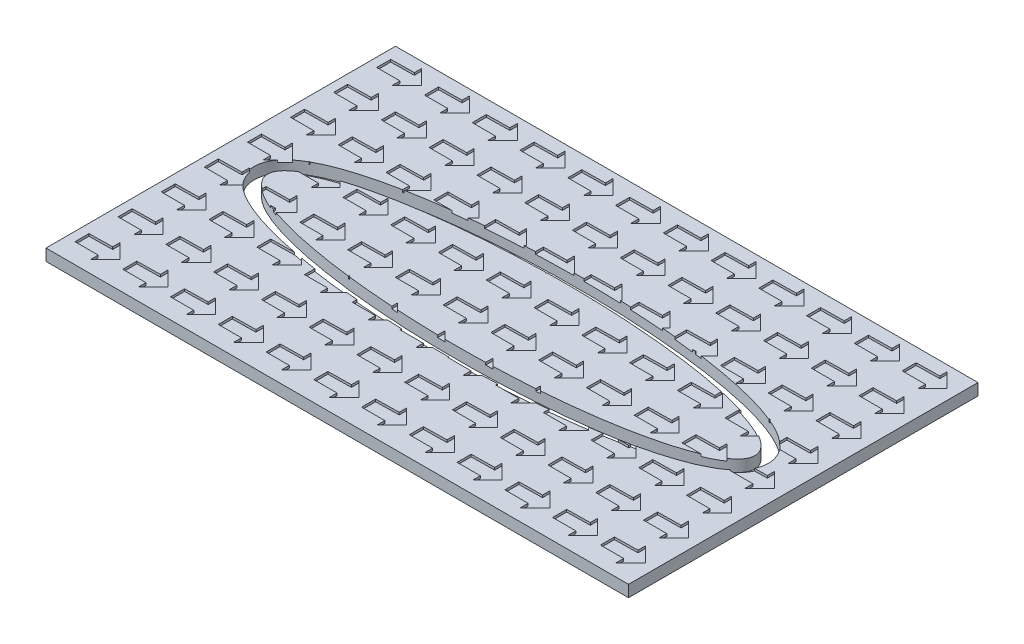
from build123d import *

# Parameters (mm, degrees)
SKETCH1_W           = 250
SKETCH1_H           = 150
BOSS_EXTRUDE1_DEPTH = 5
SKETCH2_RX          = 104.608369869
SKETCH2_RY          = 23.310401113
CUT_EXTRUDE1_DEPTH  = 5
CUT_EXTRUDE2_DEPTH  = 1


with BuildPart() as part:
    # Sketch1 → Boss-Extrude1 (new body)
    with BuildSketch(Plane(origin=(0, 0, 0), x_dir=(1, 0, 0), z_dir=(0, 1, 0))):
        with Locations((125, 75)):
            Rectangle(SKETCH1_W, SKETCH1_H)
    extrude(amount=BOSS_EXTRUDE1_DEPTH)

    # Sketch2 → Cut-Extrude1 (cut)
    with BuildSketch(Plane(origin=(0, 5, 0), x_dir=(1, 0, 0), z_dir=(0, 1, 0))):
        with BuildLine():
            add(Edge.make_bspline(
                [(14.340715902, 75), (14.340715902, 73.403382878), (15.092578894, 70.210148633), (17.677509801, 66.497889699), (21.067661583, 63.528997923), (25.203326141, 60.970996136), (30.102573384, 58.669625264), (37.666753171, 55.861830063), (49.028889113, 52.784952356), (65.375714852, 49.798065003), (83.889689518, 47.594262181), (103.910053835, 46.241449203), (124.701337221, 45.785296554), (145.492620606, 46.241449203), (165.512984923, 47.594262181), (184.026959589, 49.798065003), (200.373785328, 52.784952356), (211.73592127, 55.861830063), (219.300101057, 58.669625264), (224.199348301, 60.970996136), (228.335012859, 63.528997923), (231.725164641, 66.497889699), (234.310095547, 70.210148633), (235.437890036, 75), (234.310095547, 79.789851367), (231.725164641, 83.502110301), (228.335012859, 86.471002077), (224.199348301, 89.029003864), (219.300101057, 91.330374736), (211.73592127, 94.138169937), (200.373785328, 97.215047644), (184.026959589, 100.201934997), (165.512984923, 102.405737819), (145.492620606, 103.758550797), (124.701337221, 104.214703446), (103.910053835, 103.758550797), (83.889689518, 102.405737819), (65.375714852, 100.201934997), (49.028889113, 97.215047644), (37.666753171, 94.138169937), (30.102573384, 91.330374736), (25.203326141, 89.029003864), (21.067661583, 86.471002077), (17.677509801, 83.502110301), (15.092578894, 79.789851367), (14.340715902, 76.596617122), (14.340715902, 75)],
                knots=[0, 0, 0, 0, 0.09817477, 0.196349541, 0.294524311, 0.392699082, 0.490873852, 0.589048623, 0.785398163, 0.981747704, 1.178097245, 1.374446786, 1.570796327, 1.767145868, 1.963495408, 2.159844949, 2.35619449, 2.552544031, 2.650718801, 2.748893572, 2.847068342, 2.945243113, 3.043417883, 3.141592654, 3.239767424, 3.337942194, 3.436116965, 3.534291735, 3.632466506, 3.730641276, 3.926990817, 4.123340358, 4.319689899, 4.51603944, 4.71238898, 4.908738521, 5.105088062, 5.301437603, 5.497787144, 5.694136685, 5.792311455, 5.890486225, 5.988660996, 6.086835766, 6.185010537, 6.283185307, 6.283185307, 6.283185307, 6.283185307], degree=3))
        make_face()
        with Locations((124.701337221, 75)):
            Ellipse(SKETCH2_RX, SKETCH2_RY, mode=Mode.SUBTRACT)
    extrude(amount=-CUT_EXTRUDE1_DEPTH, mode=Mode.SUBTRACT)


with BuildPart() as cut_extrude1_piece_1:
    # of the separate pieces the step leaves, piece 1, a body of its own (cut_extrude1_pieces)
    add(part.part.solids().sort_by_distance((0, 0, 0))[0])


with BuildPart() as cut_extrude1_piece_2:
    # of the separate pieces the step leaves, piece 2, a body of its own (cut_extrude1_pieces)
    add(part.part.solids().sort_by_distance((229.30970709, 0, -75))[0])


with BuildPart() as cut_extrude2_tool:
    # Sketch3 → Cut-Extrude2 (new body)
    with BuildSketch(Plane(origin=(0, 5, 0), x_dir=(1, 0, 0), z_dir=(0, 1, 0))):
        Polygon((3.872279996, 144.087272639), (3.872279996, 138.072450962), (13.844221197, 138.072450962), (13.844221197, 134.748470562), (20.175612436, 141.079861801), (13.844221197, 147.411253039), (13.844221197, 144.24555742), align=None)
        Polygon((24.372279996, 144.087272639), (24.372279996, 138.072450962), (34.344221197, 138.072450962), (34.344221197, 134.748470562), (40.675612436, 141.079861801), (34.344221197, 147.411253039), (34.344221197, 144.24555742), align=None)
        Polygon((44.872279996, 144.087272639), (44.872279996, 138.072450962), (54.844221197, 138.072450962), (54.844221197, 134.748470562), (61.175612436, 141.079861801), (54.844221197, 147.411253039), (54.844221197, 144.24555742), align=None)
        Polygon((65.372279996, 144.087272639), (65.372279996, 138.072450962), (75.344221197, 138.072450962), (75.344221197, 134.748470562), (81.675612436, 141.079861801), (75.344221197, 147.411253039), (75.344221197, 144.24555742), align=None)
        Polygon((85.872279996, 144.087272639), (85.872279996, 138.072450962), (95.844221197, 138.072450962), (95.844221197, 134.748470562), (102.175612436, 141.079861801), (95.844221197, 147.411253039), (95.844221197, 144.24555742), align=None)
        Polygon((106.372279996, 144.087272639), (106.372279996, 138.072450962), (116.344221197, 138.072450962), (116.344221197, 134.748470562), (122.675612436, 141.079861801), (116.344221197, 147.411253039), (116.344221197, 144.24555742), align=None)
        Polygon((126.872279996, 144.087272639), (126.872279996, 138.072450962), (136.844221197, 138.072450962), (136.844221197, 134.748470562), (143.175612436, 141.079861801), (136.844221197, 147.411253039), (136.844221197, 144.24555742), align=None)
        Polygon((147.372279996, 144.087272639), (147.372279996, 138.072450962), (157.344221197, 138.072450962), (157.344221197, 134.748470562), (163.675612435, 141.079861801), (157.344221197, 147.411253039), (157.344221197, 144.24555742), align=None)
        Polygon((167.872279996, 144.087272639), (167.872279996, 138.072450962), (177.844221197, 138.072450962), (177.844221197, 134.748470562), (184.175612435, 141.079861801), (177.844221197, 147.411253039), (177.844221197, 144.24555742), align=None)
        Polygon((188.372279996, 144.087272639), (188.372279996, 138.072450962), (198.344221197, 138.072450962), (198.344221197, 134.748470562), (204.675612435, 141.079861801), (198.344221197, 147.411253039), (198.344221197, 144.24555742), align=None)
        Polygon((208.872279996, 144.087272639), (208.872279996, 138.072450962), (218.844221197, 138.072450962), (218.844221197, 134.748470562), (225.175612435, 141.079861801), (218.844221197, 147.411253039), (218.844221197, 144.24555742), align=None)
        Polygon((229.372279996, 144.087272639), (229.372279996, 138.072450962), (239.344221197, 138.072450962), (239.344221197, 134.748470562), (245.675612435, 141.079861801), (239.344221197, 147.411253039), (239.344221197, 144.24555742), align=None)
        Polygon((24.372279996, 125.587272639), (24.372279996, 119.572450962), (34.344221197, 119.572450962), (34.344221197, 116.248470562), (40.675612436, 122.579861801), (34.344221197, 128.911253039), (34.344221197, 125.74555742), align=None)
        Polygon((44.872279996, 125.587272639), (44.872279996, 119.572450962), (54.844221197, 119.572450962), (54.844221197, 116.248470562), (61.175612436, 122.579861801), (54.844221197, 128.911253039), (54.844221197, 125.74555742), align=None)
        Polygon((65.372279996, 125.587272639), (65.372279996, 119.572450962), (75.344221197, 119.572450962), (75.344221197, 116.248470562), (81.675612436, 122.579861801), (75.344221197, 128.911253039), (75.344221197, 125.74555742), align=None)
        Polygon((85.872279996, 125.587272639), (85.872279996, 119.572450962), (95.844221197, 119.572450962), (95.844221197, 116.248470562), (102.175612436, 122.579861801), (95.844221197, 128.911253039), (95.844221197, 125.74555742), align=None)
        Polygon((106.372279996, 125.587272639), (106.372279996, 119.572450962), (116.344221197, 119.572450962), (116.344221197, 116.248470562), (122.675612436, 122.579861801), (116.344221197, 128.911253039), (116.344221197, 125.74555742), align=None)
        Polygon((126.872279996, 125.587272639), (126.872279996, 119.572450962), (136.844221197, 119.572450962), (136.844221197, 116.248470562), (143.175612436, 122.579861801), (136.844221197, 128.911253039), (136.844221197, 125.74555742), align=None)
        Polygon((147.372279996, 125.587272639), (147.372279996, 119.572450962), (157.344221197, 119.572450962), (157.344221197, 116.248470562), (163.675612435, 122.579861801), (157.344221197, 128.911253039), (157.344221197, 125.74555742), align=None)
        Polygon((167.872279996, 125.587272639), (167.872279996, 119.572450962), (177.844221197, 119.572450962), (177.844221197, 116.248470562), (184.175612435, 122.579861801), (177.844221197, 128.911253039), (177.844221197, 125.74555742), align=None)
        Polygon((188.372279996, 125.587272639), (188.372279996, 119.572450962), (198.344221197, 119.572450962), (198.344221197, 116.248470562), (204.675612435, 122.579861801), (198.344221197, 128.911253039), (198.344221197, 125.74555742), align=None)
        Polygon((208.872279996, 125.587272639), (208.872279996, 119.572450962), (218.844221197, 119.572450962), (218.844221197, 116.248470562), (225.175612435, 122.579861801), (218.844221197, 128.911253039), (218.844221197, 125.74555742), align=None)
        Polygon((229.372279996, 125.587272639), (229.372279996, 119.572450962), (239.344221197, 119.572450962), (239.344221197, 116.248470562), (245.675612435, 122.579861801), (239.344221197, 128.911253039), (239.344221197, 125.74555742), align=None)
        Polygon((24.372279996, 107.087272639), (24.372279996, 101.072450962), (34.344221197, 101.072450962), (34.344221197, 97.748470562), (40.675612436, 104.079861801), (34.344221197, 110.411253039), (34.344221197, 107.24555742), align=None)
        Polygon((44.872279996, 107.087272639), (44.872279996, 101.072450962), (54.844221197, 101.072450962), (54.844221197, 97.748470562), (61.175612436, 104.079861801), (54.844221197, 110.411253039), (54.844221197, 107.24555742), align=None)
        Polygon((65.372279996, 107.087272639), (65.372279996, 101.072450962), (75.344221197, 101.072450962), (75.344221197, 97.748470562), (81.675612436, 104.079861801), (75.344221197, 110.411253039), (75.344221197, 107.24555742), align=None)
        Polygon((85.872279996, 107.087272639), (85.872279996, 101.072450962), (95.844221197, 101.072450962), (95.844221197, 97.748470562), (102.175612436, 104.079861801), (95.844221197, 110.411253039), (95.844221197, 107.24555742), align=None)
        Polygon((106.372279996, 107.087272639), (106.372279996, 101.072450962), (116.344221197, 101.072450962), (116.344221197, 97.748470562), (122.675612436, 104.079861801), (116.344221197, 110.411253039), (116.344221197, 107.24555742), align=None)
        Polygon((126.872279996, 107.087272639), (126.872279996, 101.072450962), (136.844221197, 101.072450962), (136.844221197, 97.748470562), (143.175612436, 104.079861801), (136.844221197, 110.411253039), (136.844221197, 107.24555742), align=None)
        Polygon((147.372279996, 107.087272639), (147.372279996, 101.072450962), (157.344221197, 101.072450962), (157.344221197, 97.748470562), (163.675612436, 104.079861801), (157.344221197, 110.411253039), (157.344221197, 107.24555742), align=None)
        Polygon((167.872279996, 107.087272639), (167.872279996, 101.072450962), (177.844221197, 101.072450962), (177.844221197, 97.748470562), (184.175612435, 104.079861801), (177.844221197, 110.411253039), (177.844221197, 107.24555742), align=None)
        Polygon((188.372279996, 107.087272639), (188.372279996, 101.072450962), (198.344221197, 101.072450962), (198.344221197, 97.748470562), (204.675612435, 104.079861801), (198.344221197, 110.411253039), (198.344221197, 107.24555742), align=None)
        Polygon((208.872279996, 107.087272639), (208.872279996, 101.072450962), (218.844221197, 101.072450962), (218.844221197, 97.748470562), (225.175612435, 104.079861801), (218.844221197, 110.411253039), (218.844221197, 107.24555742), align=None)
        Polygon((229.372279996, 107.087272639), (229.372279996, 101.072450962), (239.344221197, 101.072450962), (239.344221197, 97.748470562), (245.675612435, 104.079861801), (239.344221197, 110.411253039), (239.344221197, 107.24555742), align=None)
        Polygon((24.372279996, 88.587272639), (24.372279996, 82.572450962), (34.344221197, 82.572450962), (34.344221197, 79.248470562), (40.675612436, 85.579861801), (34.344221197, 91.911253039), (34.344221197, 88.74555742), align=None)
        Polygon((44.872279996, 88.587272639), (44.872279996, 82.572450962), (54.844221197, 82.572450962), (54.844221197, 79.248470562), (61.175612436, 85.579861801), (54.844221197, 91.911253039), (54.844221197, 88.74555742), align=None)
        Polygon((65.372279996, 88.587272639), (65.372279996, 82.572450962), (75.344221197, 82.572450962), (75.344221197, 79.248470562), (81.675612436, 85.579861801), (75.344221197, 91.911253039), (75.344221197, 88.74555742), align=None)
        Polygon((85.872279996, 88.587272639), (85.872279996, 82.572450962), (95.844221197, 82.572450962), (95.844221197, 79.248470562), (102.175612436, 85.579861801), (95.844221197, 91.911253039), (95.844221197, 88.74555742), align=None)
        Polygon((106.372279996, 88.587272639), (106.372279996, 82.572450962), (116.344221197, 82.572450962), (116.344221197, 79.248470562), (122.675612436, 85.579861801), (116.344221197, 91.911253039), (116.344221197, 88.74555742), align=None)
        Polygon((126.872279996, 88.587272639), (126.872279996, 82.572450962), (136.844221197, 82.572450962), (136.844221197, 79.248470562), (143.175612436, 85.579861801), (136.844221197, 91.911253039), (136.844221197, 88.74555742), align=None)
        Polygon((147.372279996, 88.587272639), (147.372279996, 82.572450962), (157.344221197, 82.572450962), (157.344221197, 79.248470562), (163.675612436, 85.579861801), (157.344221197, 91.911253039), (157.344221197, 88.74555742), align=None)
        Polygon((167.872279996, 88.587272639), (167.872279996, 82.572450962), (177.844221197, 82.572450962), (177.844221197, 79.248470562), (184.175612435, 85.579861801), (177.844221197, 91.911253039), (177.844221197, 88.74555742), align=None)
        Polygon((188.372279996, 88.587272639), (188.372279996, 82.572450962), (198.344221197, 82.572450962), (198.344221197, 79.248470562), (204.675612435, 85.579861801), (198.344221197, 91.911253039), (198.344221197, 88.74555742), align=None)
        Polygon((208.872279996, 88.587272639), (208.872279996, 82.572450962), (218.844221197, 82.572450962), (218.844221197, 79.248470562), (225.175612435, 85.579861801), (218.844221197, 91.911253039), (218.844221197, 88.74555742), align=None)
        Polygon((229.372279996, 88.587272639), (229.372279996, 82.572450962), (239.344221197, 82.572450962), (239.344221197, 79.248470562), (245.675612435, 85.579861801), (239.344221197, 91.911253039), (239.344221197, 88.74555742), align=None)
        Polygon((24.372279996, 70.087272639), (24.372279996, 64.072450962), (34.344221197, 64.072450962), (34.344221197, 60.748470562), (40.675612436, 67.079861801), (34.344221197, 73.411253039), (34.344221197, 70.24555742), align=None)
        Polygon((44.872279996, 70.087272639), (44.872279996, 64.072450962), (54.844221197, 64.072450962), (54.844221197, 60.748470562), (61.175612436, 67.079861801), (54.844221197, 73.411253039), (54.844221197, 70.24555742), align=None)
        Polygon((65.372279996, 70.087272639), (65.372279996, 64.072450962), (75.344221197, 64.072450962), (75.344221197, 60.748470562), (81.675612436, 67.079861801), (75.344221197, 73.411253039), (75.344221197, 70.24555742), align=None)
        Polygon((85.872279996, 70.087272639), (85.872279996, 64.072450962), (95.844221197, 64.072450962), (95.844221197, 60.748470562), (102.175612436, 67.079861801), (95.844221197, 73.411253039), (95.844221197, 70.24555742), align=None)
        Polygon((106.372279996, 70.087272639), (106.372279996, 64.072450962), (116.344221197, 64.072450962), (116.344221197, 60.748470562), (122.675612436, 67.079861801), (116.344221197, 73.411253039), (116.344221197, 70.24555742), align=None)
        Polygon((126.872279996, 70.087272639), (126.872279996, 64.072450962), (136.844221197, 64.072450962), (136.844221197, 60.748470562), (143.175612436, 67.079861801), (136.844221197, 73.411253039), (136.844221197, 70.24555742), align=None)
        Polygon((147.372279996, 70.087272639), (147.372279996, 64.072450962), (157.344221197, 64.072450962), (157.344221197, 60.748470562), (163.675612436, 67.079861801), (157.344221197, 73.411253039), (157.344221197, 70.24555742), align=None)
        Polygon((167.872279996, 70.087272639), (167.872279996, 64.072450962), (177.844221197, 64.072450962), (177.844221197, 60.748470562), (184.175612435, 67.079861801), (177.844221197, 73.411253039), (177.844221197, 70.24555742), align=None)
        Polygon((188.372279996, 70.087272639), (188.372279996, 64.072450962), (198.344221197, 64.072450962), (198.344221197, 60.748470562), (204.675612435, 67.079861801), (198.344221197, 73.411253039), (198.344221197, 70.24555742), align=None)
        Polygon((208.872279996, 70.087272639), (208.872279996, 64.072450962), (218.844221197, 64.072450962), (218.844221197, 60.748470562), (225.175612435, 67.079861801), (218.844221197, 73.411253039), (218.844221197, 70.24555742), align=None)
        Polygon((229.372279996, 70.087272639), (229.372279996, 64.072450962), (239.344221197, 64.072450962), (239.344221197, 60.748470562), (245.675612435, 67.079861801), (239.344221197, 73.411253039), (239.344221197, 70.24555742), align=None)
        Polygon((24.372279996, 51.587272639), (24.372279996, 45.572450962), (34.344221197, 45.572450962), (34.344221197, 42.248470562), (40.675612436, 48.579861801), (34.344221197, 54.911253039), (34.344221197, 51.74555742), align=None)
        Polygon((44.872279996, 51.587272639), (44.872279996, 45.572450962), (54.844221197, 45.572450962), (54.844221197, 42.248470562), (61.175612436, 48.579861801), (54.844221197, 54.911253039), (54.844221197, 51.74555742), align=None)
        Polygon((65.372279996, 51.587272639), (65.372279996, 45.572450962), (75.344221197, 45.572450962), (75.344221197, 42.248470562), (81.675612436, 48.579861801), (75.344221197, 54.911253039), (75.344221197, 51.74555742), align=None)
        Polygon((85.872279996, 51.587272639), (85.872279996, 45.572450962), (95.844221197, 45.572450962), (95.844221197, 42.248470562), (102.175612436, 48.579861801), (95.844221197, 54.911253039), (95.844221197, 51.74555742), align=None)
        Polygon((106.372279996, 51.587272639), (106.372279996, 45.572450962), (116.344221197, 45.572450962), (116.344221197, 42.248470562), (122.675612436, 48.579861801), (116.344221197, 54.911253039), (116.344221197, 51.74555742), align=None)
        Polygon((126.872279996, 51.587272639), (126.872279996, 45.572450962), (136.844221197, 45.572450962), (136.844221197, 42.248470562), (143.175612436, 48.579861801), (136.844221197, 54.911253039), (136.844221197, 51.74555742), align=None)
        Polygon((147.372279996, 51.587272639), (147.372279996, 45.572450962), (157.344221197, 45.572450962), (157.344221197, 42.248470562), (163.675612436, 48.579861801), (157.344221197, 54.911253039), (157.344221197, 51.74555742), align=None)
        Polygon((167.872279996, 51.587272639), (167.872279996, 45.572450962), (177.844221197, 45.572450962), (177.844221197, 42.248470562), (184.175612435, 48.579861801), (177.844221197, 54.911253039), (177.844221197, 51.74555742), align=None)
        Polygon((188.372279996, 51.587272639), (188.372279996, 45.572450962), (198.344221197, 45.572450962), (198.344221197, 42.248470562), (204.675612435, 48.579861801), (198.344221197, 54.911253039), (198.344221197, 51.74555742), align=None)
        Polygon((208.872279996, 51.587272639), (208.872279996, 45.572450962), (218.844221197, 45.572450962), (218.844221197, 42.248470562), (225.175612435, 48.579861801), (218.844221197, 54.911253039), (218.844221197, 51.74555742), align=None)
        Polygon((229.372279996, 51.587272639), (229.372279996, 45.572450962), (239.344221197, 45.572450962), (239.344221197, 42.248470562), (245.675612435, 48.579861801), (239.344221197, 54.911253039), (239.344221197, 51.74555742), align=None)
        Polygon((24.372279996, 33.087272639), (24.372279996, 27.072450962), (34.344221197, 27.072450962), (34.344221197, 23.748470562), (40.675612436, 30.079861801), (34.344221197, 36.411253039), (34.344221197, 33.24555742), align=None)
        Polygon((44.872279996, 33.087272639), (44.872279996, 27.072450962), (54.844221197, 27.072450962), (54.844221197, 23.748470562), (61.175612436, 30.079861801), (54.844221197, 36.411253039), (54.844221197, 33.24555742), align=None)
        Polygon((65.372279996, 33.087272639), (65.372279996, 27.072450962), (75.344221197, 27.072450962), (75.344221197, 23.748470562), (81.675612436, 30.079861801), (75.344221197, 36.411253039), (75.344221197, 33.24555742), align=None)
        Polygon((85.872279996, 33.087272639), (85.872279996, 27.072450962), (95.844221197, 27.072450962), (95.844221197, 23.748470562), (102.175612436, 30.079861801), (95.844221197, 36.411253039), (95.844221197, 33.24555742), align=None)
        Polygon((106.372279996, 33.087272639), (106.372279996, 27.072450962), (116.344221197, 27.072450962), (116.344221197, 23.748470562), (122.675612436, 30.079861801), (116.344221197, 36.411253039), (116.344221197, 33.24555742), align=None)
        Polygon((126.872279996, 33.087272639), (126.872279996, 27.072450962), (136.844221197, 27.072450962), (136.844221197, 23.748470562), (143.175612436, 30.079861801), (136.844221197, 36.411253039), (136.844221197, 33.24555742), align=None)
        Polygon((147.372279996, 33.087272639), (147.372279996, 27.072450962), (157.344221197, 27.072450962), (157.344221197, 23.748470562), (163.675612436, 30.079861801), (157.344221197, 36.411253039), (157.344221197, 33.24555742), align=None)
        Polygon((167.872279996, 33.087272639), (167.872279996, 27.072450962), (177.844221197, 27.072450962), (177.844221197, 23.748470562), (184.175612435, 30.079861801), (177.844221197, 36.411253039), (177.844221197, 33.24555742), align=None)
        Polygon((188.372279996, 33.087272639), (188.372279996, 27.072450962), (198.344221197, 27.072450962), (198.344221197, 23.748470562), (204.675612435, 30.079861801), (198.344221197, 36.411253039), (198.344221197, 33.24555742), align=None)
        Polygon((208.872279996, 33.087272639), (208.872279996, 27.072450962), (218.844221197, 27.072450962), (218.844221197, 23.748470562), (225.175612435, 30.079861801), (218.844221197, 36.411253039), (218.844221197, 33.24555742), align=None)
        Polygon((229.372279996, 33.087272639), (229.372279996, 27.072450962), (239.344221197, 27.072450962), (239.344221197, 23.748470562), (245.675612435, 30.079861801), (239.344221197, 36.411253039), (239.344221197, 33.24555742), align=None)
        Polygon((24.372279996, 14.587272639), (24.372279996, 8.572450962), (34.344221197, 8.572450962), (34.344221197, 5.248470562), (40.675612436, 11.579861801), (34.344221197, 17.911253039), (34.344221197, 14.74555742), align=None)
        Polygon((44.872279996, 14.587272639), (44.872279996, 8.572450962), (54.844221197, 8.572450962), (54.844221197, 5.248470562), (61.175612436, 11.579861801), (54.844221197, 17.911253039), (54.844221197, 14.74555742), align=None)
        Polygon((65.372279996, 14.587272639), (65.372279996, 8.572450962), (75.344221197, 8.572450962), (75.344221197, 5.248470562), (81.675612436, 11.579861801), (75.344221197, 17.911253039), (75.344221197, 14.74555742), align=None)
        Polygon((85.872279996, 14.587272639), (85.872279996, 8.572450962), (95.844221197, 8.572450962), (95.844221197, 5.248470562), (102.175612436, 11.579861801), (95.844221197, 17.911253039), (95.844221197, 14.74555742), align=None)
        Polygon((106.372279996, 14.587272639), (106.372279996, 8.572450962), (116.344221197, 8.572450962), (116.344221197, 5.248470562), (122.675612436, 11.579861801), (116.344221197, 17.911253039), (116.344221197, 14.74555742), align=None)
        Polygon((126.872279996, 14.587272639), (126.872279996, 8.572450962), (136.844221197, 8.572450962), (136.844221197, 5.248470562), (143.175612436, 11.579861801), (136.844221197, 17.911253039), (136.844221197, 14.74555742), align=None)
        Polygon((147.372279996, 14.587272639), (147.372279996, 8.572450962), (157.344221197, 8.572450962), (157.344221197, 5.248470562), (163.675612436, 11.579861801), (157.344221197, 17.911253039), (157.344221197, 14.74555742), align=None)
        Polygon((167.872279996, 14.587272639), (167.872279996, 8.572450962), (177.844221197, 8.572450962), (177.844221197, 5.248470562), (184.175612435, 11.579861801), (177.844221197, 17.911253039), (177.844221197, 14.74555742), align=None)
        Polygon((188.372279996, 14.587272639), (188.372279996, 8.572450962), (198.344221197, 8.572450962), (198.344221197, 5.248470562), (204.675612435, 11.579861801), (198.344221197, 17.911253039), (198.344221197, 14.74555742), align=None)
        Polygon((208.872279996, 14.587272639), (208.872279996, 8.572450962), (218.844221197, 8.572450962), (218.844221197, 5.248470562), (225.175612435, 11.579861801), (218.844221197, 17.911253039), (218.844221197, 14.74555742), align=None)
        Polygon((229.372279996, 14.587272639), (229.372279996, 8.572450962), (239.344221197, 8.572450962), (239.344221197, 5.248470562), (245.675612435, 11.579861801), (239.344221197, 17.911253039), (239.344221197, 14.74555742), align=None)
        Polygon((3.872279996, 125.587272639), (3.872279996, 119.572450962), (13.844221197, 119.572450962), (13.844221197, 116.248470562), (20.175612436, 122.579861801), (13.844221197, 128.911253039), (13.844221197, 125.74555742), align=None)
        Polygon((3.872279996, 107.087272639), (3.872279996, 101.072450962), (13.844221197, 101.072450962), (13.844221197, 97.748470562), (20.175612436, 104.079861801), (13.844221197, 110.411253039), (13.844221197, 107.24555742), align=None)
        Polygon((3.872279996, 88.587272639), (3.872279996, 82.572450962), (13.844221197, 82.572450962), (13.844221197, 79.248470562), (20.175612436, 85.579861801), (13.844221197, 91.911253039), (13.844221197, 88.74555742), align=None)
        Polygon((3.872279996, 70.087272639), (3.872279996, 64.072450962), (13.844221197, 64.072450962), (13.844221197, 60.748470562), (20.175612436, 67.079861801), (13.844221197, 73.411253039), (13.844221197, 70.24555742), align=None)
        Polygon((3.872279996, 51.587272639), (3.872279996, 45.572450962), (13.844221197, 45.572450962), (13.844221197, 42.248470562), (20.175612436, 48.579861801), (13.844221197, 54.911253039), (13.844221197, 51.74555742), align=None)
        Polygon((3.872279996, 33.087272639), (3.872279996, 27.072450962), (13.844221197, 27.072450962), (13.844221197, 23.748470562), (20.175612436, 30.079861801), (13.844221197, 36.411253039), (13.844221197, 33.24555742), align=None)
        Polygon((3.872279996, 14.587272639), (3.872279996, 8.572450962), (13.844221197, 8.572450962), (13.844221197, 5.248470562), (20.175612436, 11.579861801), (13.844221197, 17.911253039), (13.844221197, 14.74555742), align=None)
    extrude(amount=-CUT_EXTRUDE2_DEPTH)


with BuildPart() as cut_extrude1_piece_1_1:
    add(cut_extrude1_piece_1.part)

    # Cut-Extrude2: cut by cut_extrude2_tool
    add(cut_extrude2_tool.part, mode=Mode.SUBTRACT)


with BuildPart() as cut_extrude1_piece_2_1:
    add(cut_extrude1_piece_2.part)

    # Cut-Extrude2: cut by cut_extrude2_tool
    add(cut_extrude2_tool.part, mode=Mode.SUBTRACT)


solid = Compound([cut_extrude1_piece_1_1.part, cut_extrude1_piece_2_1.part])
